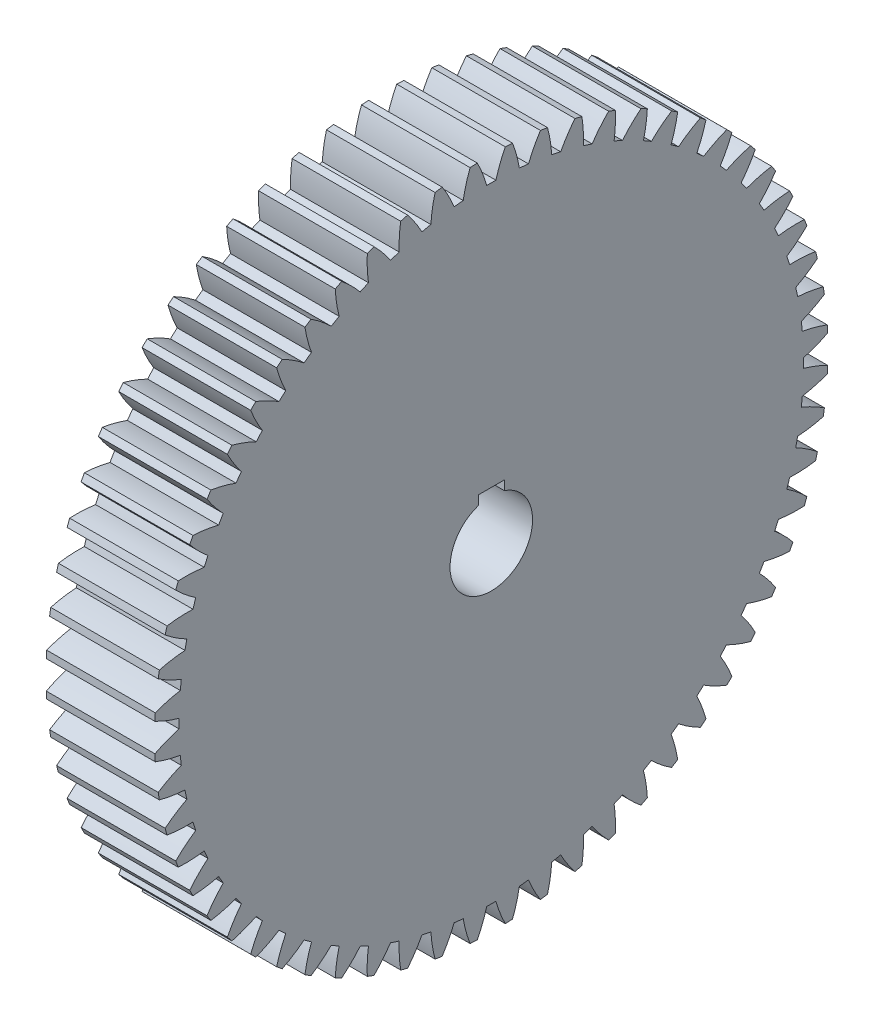
from build123d import *

# Parameters (mm, degrees)
BASPROSKE_W     = 50
BASPROSKE_H     = 155
TOOTHCUT_DEPTH  = 225.833271559
TEETHCUTS_COUNT = 60
TEETHCUTS_ANGLE = 354
BORSKE_R        = 19
BORE_DEPTH      = 50.0000508
KEYSKE_W        = 12
KEYSKE_H        = 22.3
KEYWAY_DEPTH    = 50.0000508


with BuildPart() as part:
    # BasProSke → Base-Revolve (revolve)
    with BuildSketch(Plane(origin=(0, 0, 0), x_dir=(1, 0, 0), z_dir=(0, 1, 0)), mode=Mode.PRIVATE) as base_revolve_sk:
        with Locations((25, 77.5)):
            Rectangle(BASPROSKE_W, BASPROSKE_H)
    revolve(base_revolve_sk.sketch.rotate(Axis((-10, 0, 0), (1, 0, 0)), 180), axis=Axis((-10, 0, 0), (1, 0, 0)))

    # TooCutSke → ToothCut (cut, through all)
    with BuildSketch(Plane(origin=(0, 0, 0), x_dir=(0, 0, -1), z_dir=(1, 0, 0))):
        with BuildLine():
            ThreePointArc((2.113293984, 143.7334651), (0, 143.749), (-2.113293984, 143.7334651))
            ThreePointArc((-2.113293984, 143.7334651), (-4.012971711, 149.420886614), (-6.470843563, 154.890292881))
            ThreePointArc((-6.470843563, 154.890292881), (0, 155.0254), (6.470843563, 154.890292881))
            ThreePointArc((6.470843563, 154.890292881), (4.012971711, 149.420886614), (2.113293984, 143.7334651))
        make_face()
    toothcut = extrude(amount=TOOTHCUT_DEPTH, mode=Mode.SUBTRACT)

    # TeethCuts: ToothCut ×60 about axis
    teethcuts_axis = Axis((-10, 0, 0), (1, 0, 0))
    for i in range(1, TEETHCUTS_COUNT):
        add(toothcut.rotate(teethcuts_axis, i * TEETHCUTS_ANGLE / (TEETHCUTS_COUNT - 1)), mode=Mode.SUBTRACT)

    # BorSke → Bore (cut, symmetric)
    with BuildSketch(Plane(origin=(0, 0, 0), x_dir=(0, 0, -1), z_dir=(1, 0, 0))):
        with Locations(Location((0, 0, 0), (0, 0, 180))):
            Circle(BORSKE_R)
    extrude(amount=BORE_DEPTH, both=True, mode=Mode.SUBTRACT)

    # KeySke → Keyway (cut, symmetric)
    with BuildSketch(Plane(origin=(0, 0, 0), x_dir=(0, 0, -1), z_dir=(1, 0, 0))):
        with Locations((0, 11.15)):
            Rectangle(KEYSKE_W, KEYSKE_H)
    extrude(amount=KEYWAY_DEPTH, both=True, mode=Mode.SUBTRACT)


solid = part.part
